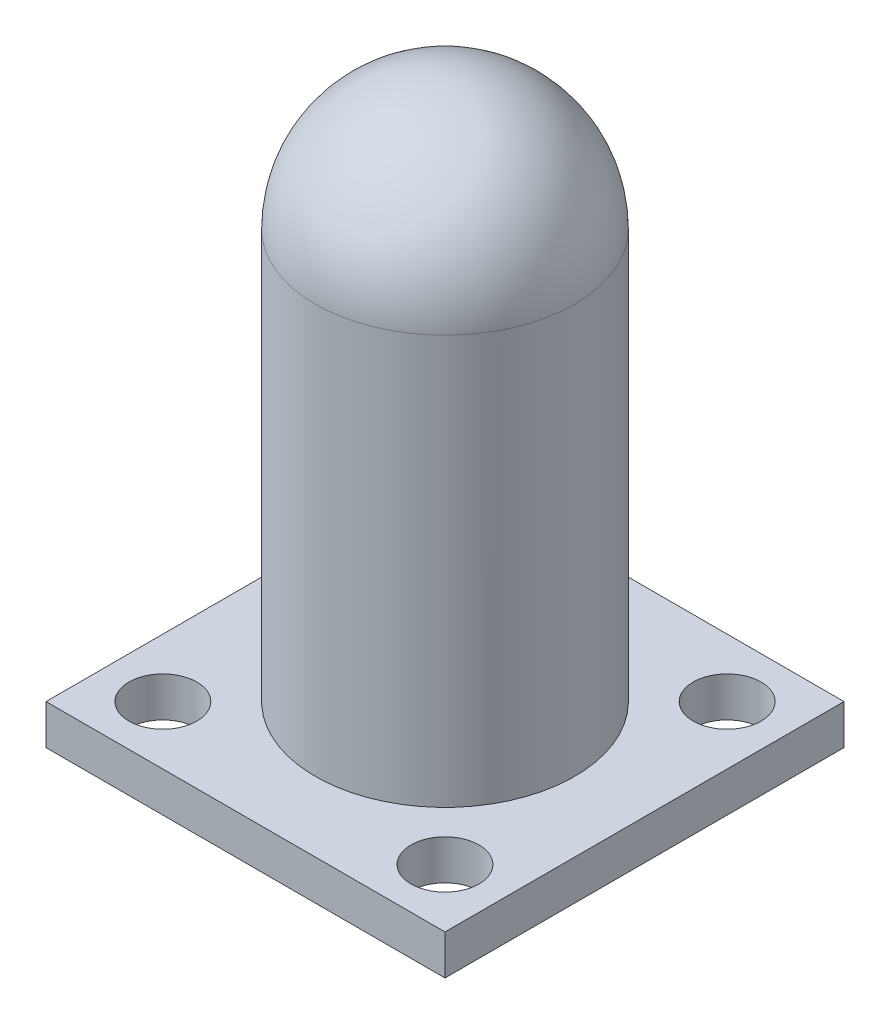
from build123d import *

# Parameters (mm, degrees)
ESQUISSE3_W          = 20
ESQUISSE3_H          = 20
BOSS_EXTRU_1_DEPTH   = 2
D_GAGEMENT_M31_D     = 3.4
D_GAGEMENT_M31_DEPTH = 3
D_GAGEMENT_M31_TIP   = 1.021463052


with BuildPart() as part:
    # Esquisse2 → Révolution3 (revolve)
    with BuildSketch(Plane.XY):
        with BuildLine():
            Line((4, 0), (6.5, 0))
            Line((6.5, 0), (6.5, 20.5))
            ThreePointArc((6.5, 20.5), (4.596194078, 25.096194078), (0, 27))
            Line((0, 27), (0, 25.944271904))
            Line((0, 25.944271904), (0, 24.5))
            ThreePointArc((0, 24.5), (2.828427125, 23.328427125), (4, 20.5))
            Line((4, 20.5), (4, 0))
        make_face()
    revolve(axis=Axis((0, 0, 0), (0, 1, 0)))

    # Esquisse3 → Boss.-Extru.1 (add)
    with BuildSketch(Plane.XZ):
        Rectangle(ESQUISSE3_W, ESQUISSE3_H)
    extrude(amount=BOSS_EXTRU_1_DEPTH)

    # Dégagement M31
    with Locations(Plane(origin=(0, 0, 0), x_dir=(1, 0, 0), z_dir=(0, 1, 0))):
        with Locations((-7.071067812, 7.071067812), (7.071067812, 7.071067812), (7.071067812, -7.071067812), (-7.071067812, -7.071067812)):
            Hole(D_GAGEMENT_M31_D / 2, depth=D_GAGEMENT_M31_DEPTH)
            with Locations((0, 0, -(D_GAGEMENT_M31_DEPTH + D_GAGEMENT_M31_TIP / 2))):  # 118° drill point
                Cone(0, D_GAGEMENT_M31_D / 2, D_GAGEMENT_M31_TIP, mode=Mode.SUBTRACT)


solid = part.part
